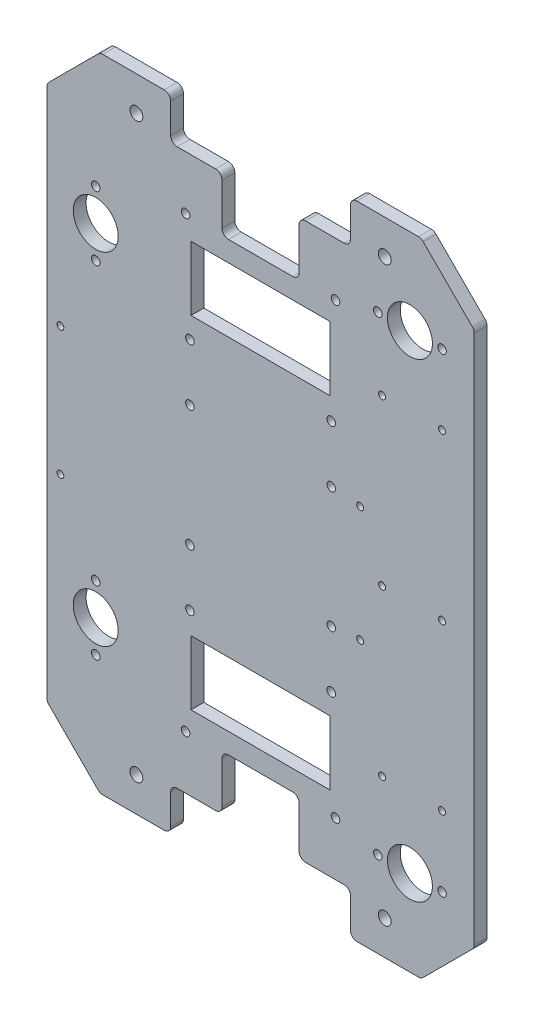
from build123d import *

# Parameters (mm, degrees)
BASE_DEPTH                     = 6
ESQUISSE3_R                    = 2
ESQUISSE3_W                    = 65
ESQUISSE3_H                    = 30
ENL_V_MAT_EXTRU_1_DEPTH        = 10
CONG_1_R                       = 3
ESQUISSE6_R                    = 2
ESQUISSE6_R_2                  = 10.5
PER_AGE_POUR_BILLES_DEPTH      = 10
PER_AGE_POUR_BILLES_DEPTH_BACK = 10
ESQUISSE8_R                    = 3
PER_AGE_POUR_PROFIL_DEPTH      = 10
PER_AGE_POUR_PROFIL_DEPTH_BACK = 10
ESQUISSE10_R                   = 2
ESQUISSE10_R_2                 = 1.6
ESQUISSE10_R_3                 = 1.625
ENL_V_MAT_EXTRU_3_DEPTH        = 10
ENL_V_MAT_EXTRU_3_DEPTH_BACK   = 10


with BuildPart() as part:
    # Esquisse1 → Base (new body)
    with BuildSketch(Plane.XY):
        Polygon((24.748737342, 24.748737342), (0, 0), (-150, 0), (-174.748737342, 24.748737342), (-174.748737342, 274.748737342), (-150, 299.497474683), (0, 299.497474683), (24.748737342, 274.748737342), align=None)
    extrude(amount=BASE_DEPTH)

    # Esquisse3 → Enlèv. mat.-Extru.1 (cut)
    with BuildSketch(Plane(origin=(0, 0, 0), x_dir=(-1, 0, 0), z_dir=(0, 0, -1))):
        with Locations((40, 45)):
            Circle(ESQUISSE3_R)
        with Locations((110, 45)):
            Circle(ESQUISSE3_R)
        with Locations((110, 254.497474683)):
            Circle(ESQUISSE3_R)
        with Locations((40, 254.497474683)):
            Circle(ESQUISSE3_R)
        Polygon((117, 0), (117, 20), (93, 20), (93, 45.5), (57, 45.5), (57, 20), (33, 20), (33, 0), align=None)
        Polygon((33, 299.497474683), (117, 299.497474683), (117, 279.497474683), (93, 279.497474683), (93, 253.997474683), (57, 253.997474683), (57, 279.497474683), (33, 279.497474683), align=None)
        with Locations((75, 229.497474683)):
            Rectangle(ESQUISSE3_W, ESQUISSE3_H)
        with Locations((75, 70)):
            Rectangle(ESQUISSE3_W, ESQUISSE3_H)
    extrude(amount=-ENL_V_MAT_EXTRU_1_DEPTH, mode=Mode.SUBTRACT)

    # Congé1
    cong_1_edges = [part.edges().sort_by_distance(p)[0] for p in [
        (-117, 0, 3),
        (-33, 0, 3),
        (-33, 20, 3),
        (-57, 20, 3),
        (-57, 45.5, 3),
        (-93, 45.5, 3),
        (-93, 20, 3),
        (-117, 20, 3),
        (0, 0, 3),
        (-150, 0, 3),
        (-174.748737342, 24.748737342, 3),
        (-174.748737342, 274.748737342, 3),
        (-150, 299.497474683, 3),
        (0, 299.497474683, 3),
        (24.748737342, 274.748737342, 3),
        (24.748737342, 24.748737342, 3),
        (-33, 279.497474683, 3),
        (-33, 299.497474683, 3),
        (-117, 299.497474683, 3),
        (-117, 279.497474683, 3),
        (-93, 279.497474683, 3),
        (-93, 253.997474683, 3),
        (-57, 253.997474683, 3),
        (-57, 279.497474683, 3),
    ]]
    fillet(cong_1_edges, radius=CONG_1_R)

    # Esquisse6 → Perçage pour billes (cut, two sides)
    with BuildSketch(Plane.XY.offset(5)) as per_age_pour_billes_sk:
        with Locations((-152, 55)):
            Circle(ESQUISSE6_R)
        with Locations((-152, 85)):
            Circle(ESQUISSE6_R)
        with Locations((-152, 70)):
            Circle(ESQUISSE6_R_2)
        with Locations((-152, 244.497474683)):
            Circle(ESQUISSE6_R)
        with Locations((-152, 214.497474683)):
            Circle(ESQUISSE6_R)
        with Locations((-152, 229.497474683)):
            Circle(ESQUISSE6_R_2)
        with Locations((-20.251262658, 259.497474683)):
            Circle(ESQUISSE6_R)
        with Locations((-5.251262658, 259.497474683)):
            Circle(ESQUISSE6_R_2)
        with Locations((9.748737342, 259.497474683)):
            Circle(ESQUISSE6_R)
        with Locations((9.748737342, 40)):
            Circle(ESQUISSE6_R)
        with Locations((-5.251262658, 40)):
            Circle(ESQUISSE6_R_2)
        with Locations((-20.251262658, 40)):
            Circle(ESQUISSE6_R)
    extrude(amount=PER_AGE_POUR_BILLES_DEPTH, mode=Mode.SUBTRACT)
    extrude(per_age_pour_billes_sk.sketch, amount=-PER_AGE_POUR_BILLES_DEPTH_BACK, mode=Mode.SUBTRACT)

    # Esquisse8 → Perçage pour profilé (cut, two sides)
    with BuildSketch(Plane.XY.offset(5)) as per_age_pour_profil_sk:
        with Locations((-133, 16)):
            Circle(ESQUISSE8_R)
        with Locations((-133, 283.497474683)):
            Circle(ESQUISSE8_R)
        with Locations((-17, 283.497474683)):
            Circle(ESQUISSE8_R)
        with Locations((-17, 16)):
            Circle(ESQUISSE8_R)
    extrude(amount=PER_AGE_POUR_PROFIL_DEPTH, mode=Mode.SUBTRACT)
    extrude(per_age_pour_profil_sk.sketch, amount=-PER_AGE_POUR_PROFIL_DEPTH_BACK, mode=Mode.SUBTRACT)

    # Esquisse10 → Enlèv. mat.-Extru.3 (cut, two sides)
    with BuildSketch(Plane.XY.offset(5)) as enl_v_mat_extru_3_sk:
        with Locations((-108, 204.497474683)):
            Circle(ESQUISSE10_R)
        with Locations((-108, 177.997474683)):
            Circle(ESQUISSE10_R)
        with Locations((-42, 177.997474683)):
            Circle(ESQUISSE10_R)
        with Locations((-42, 204.497474683)):
            Circle(ESQUISSE10_R)
        with Locations((-42, 121.5)):
            Circle(ESQUISSE10_R)
        with Locations((-42, 95)):
            Circle(ESQUISSE10_R)
        with Locations((-108, 121.5)):
            Circle(ESQUISSE10_R)
        with Locations((-108, 95)):
            Circle(ESQUISSE10_R)
        with Locations((-28.5, 176.748737342)):
            Circle(ESQUISSE10_R_2)
        with Locations((-28.5, 122.748737342)):
            Circle(ESQUISSE10_R_2)
        with Locations((-168.498737342, 179.748737342)):
            Circle(ESQUISSE10_R_2)
        with Locations((-168.498737342, 119.748737342)):
            Circle(ESQUISSE10_R_2)
        with Locations((-18.251262658, 149.748737342)):
            Circle(ESQUISSE10_R_3)
        with Locations((9.748737342, 149.748737342)):
            Circle(ESQUISSE10_R_3)
        with Locations((9.748737342, 72.748737342)):
            Circle(ESQUISSE10_R_3)
        with Locations((9.748737342, 226.748737342)):
            Circle(ESQUISSE10_R_3)
        with Locations((-18.251262658, 72.748737342)):
            Circle(ESQUISSE10_R_3)
        with Locations((-18.251262658, 226.748737342)):
            Circle(ESQUISSE10_R_3)
    extrude(amount=ENL_V_MAT_EXTRU_3_DEPTH, mode=Mode.SUBTRACT)
    extrude(enl_v_mat_extru_3_sk.sketch, amount=-ENL_V_MAT_EXTRU_3_DEPTH_BACK, mode=Mode.SUBTRACT)


solid = part.part
